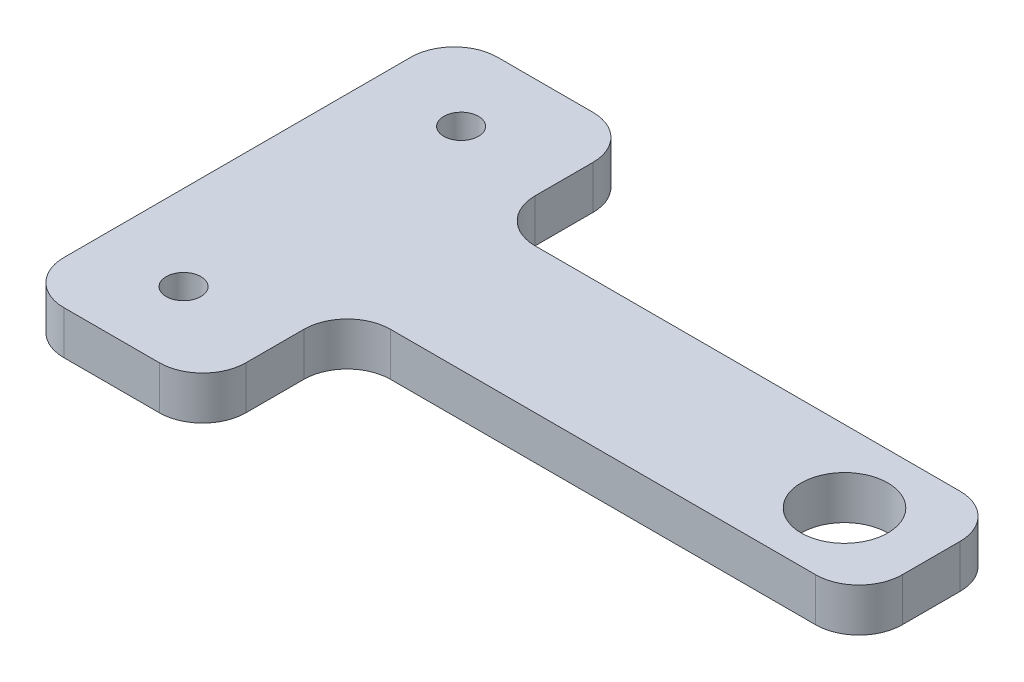
from build123d import *

# Parameters (mm, degrees)
SKETCH1_W           = 29.5
SKETCH1_H           = 8.333333334
SKETCH1_R           = 2.5
SKETCH1_R_2         = 1
BOSS_EXTRUDE1_DEPTH = 2.5
FILLET1_R           = 2.5


with BuildPart() as part:
    # Sketch1 → Boss-Extrude1 (new body)
    with BuildSketch(Plane(origin=(0, 0, 0), x_dir=(1, 0, 0), z_dir=(0, 1, 0))):
        with Locations((25.25, 12.5)):
            Rectangle(SKETCH1_W, SKETCH1_H)
        with Locations((35, 12.5)):
            Circle(SKETCH1_R, mode=Mode.SUBTRACT)
        Polygon((10.5, 25), (1.052631579, 25), (0, 25), (0, 0), (10.5, 0), (10.5, 8.333333333), (10.5, 16.666666667), align=None)
        with Locations((4.9, 4.5)):
            Circle(SKETCH1_R_2, mode=Mode.SUBTRACT)
        with Locations((4.9, 20.5)):
            Circle(SKETCH1_R_2, mode=Mode.SUBTRACT)
    extrude(amount=BOSS_EXTRUDE1_DEPTH)

    # Fillet1
    fillet1_edges = [part.edges().sort_by_distance(p)[0] for p in [
        (40, 1.25, -8.333333333),
        (10.5, 1.25, -8.333333333),
        (10.5, 1.25, 0),
        (0, 1.25, 0),
        (0, 1.25, -25),
        (10.5, 1.25, -25),
        (10.5, 1.25, -16.666666667),
        (40, 1.25, -16.666666667),
    ]]
    fillet(fillet1_edges, radius=FILLET1_R)


solid = part.part
